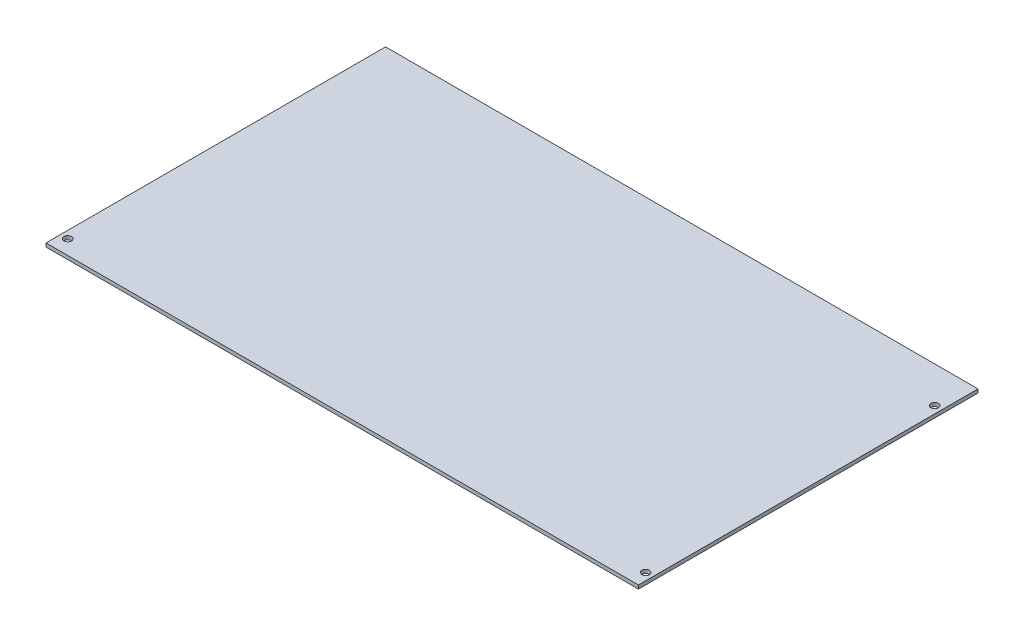
from build123d import *

# Parameters (mm, degrees)
SKETCH1_W           = 520.7
SKETCH1_H           = 298.45
BOSS_EXTRUDE1_DEPTH = 3.175
CUT_EXTRUDE1_REACH  = 5.175
SKETCH2_R           = 3.3528


with BuildPart() as part:
    # Sketch1 → Boss-Extrude1 (new body)
    with BuildSketch(Plane(origin=(0, 0, 0), x_dir=(1, 0, 0), z_dir=(0, 1, 0))):
        with Locations((260.35, 149.225)):
            Rectangle(SKETCH1_W, SKETCH1_H)
    extrude(amount=BOSS_EXTRUDE1_DEPTH)

    # Sketch2 → Cut-Extrude1 (cut, up to next)
    with BuildSketch(Plane.XZ, mode=Mode.PRIVATE) as cut_extrude1_sk1:
        with Locations((6.35, -12.7)):
            Circle(SKETCH2_R)
    cut_extrude1_tool1 = extrude(cut_extrude1_sk1.sketch, amount=-CUT_EXTRUDE1_REACH, mode=Mode.PRIVATE) & part.part
    add(cut_extrude1_tool1.solids().sort_by_distance((6.35, 0, -12.7))[0], mode=Mode.SUBTRACT)
    # Sketch2 → Cut-Extrude1 (cut, up to next)
    with BuildSketch(Plane.XZ, mode=Mode.PRIVATE) as cut_extrude1_sk2:
        with Locations((514.35, -12.7)):
            Circle(SKETCH2_R)
    cut_extrude1_tool2 = extrude(cut_extrude1_sk2.sketch, amount=-CUT_EXTRUDE1_REACH, mode=Mode.PRIVATE) & part.part
    add(cut_extrude1_tool2.solids().sort_by_distance((514.35, 0, -12.7))[0], mode=Mode.SUBTRACT)
    # Sketch2 → Cut-Extrude1 (cut, up to next)
    with BuildSketch(Plane.XZ, mode=Mode.PRIVATE) as cut_extrude1_sk3:
        with Locations((514.35, -266.7)):
            Circle(SKETCH2_R)
    cut_extrude1_tool3 = extrude(cut_extrude1_sk3.sketch, amount=-CUT_EXTRUDE1_REACH, mode=Mode.PRIVATE) & part.part
    add(cut_extrude1_tool3.solids().sort_by_distance((514.35, 0, -266.7))[0], mode=Mode.SUBTRACT)


solid = part.part
